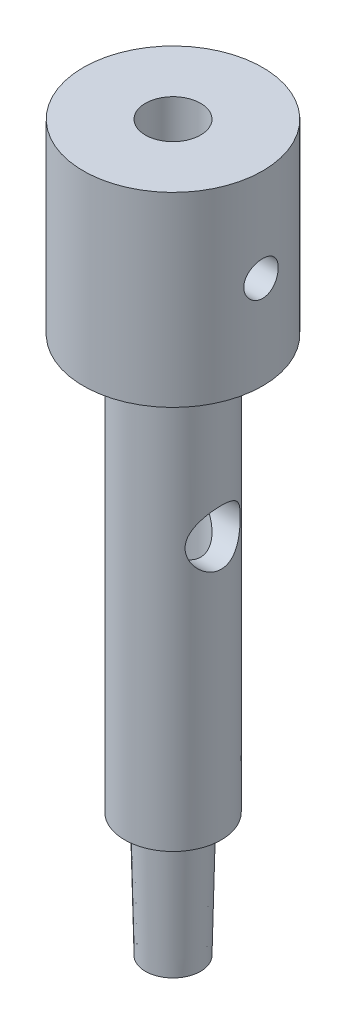
from build123d import *

# Parameters (mm, degrees)
SKETCH_2_R            = 2
CUT_EXTRUDE_1_DEPTH   = 3.5
HOLE_WIZARD_M31_D     = 2.5
HOLE_WIZARD_M31_DEPTH = 6
HOLE_WIZARD_M31_TIP   = 0.751075774


with BuildPart() as part:
    # Эскиз1 → Повернуть1 (revolve)
    with BuildSketch(Plane.XY):
        Polygon((-2, -34.780816616), (-1.25, -34.780816616), (-1.25, -19.23146208), (-2, -18.780816616), (-2, 17.719183384), (-6.5, 17.719183384), (-6.5, 4.219183384), (-3.5, 4.219183384), (-3.5, -25.780816616), (-2.2, -25.780816616), align=None)
    revolve(axis=Axis((0, 17.719183384, 0), (0, -1, 0)))

    # Эскиз2 → Вырез-Вытянуть1 (cut)
    with BuildSketch(Plane(origin=(3.5, 0, 0), x_dir=(0, 0, -1), z_dir=(1, 0, 0))):
        with Locations((0, -6.780816616)):
            Circle(SKETCH_2_R)
    extrude(amount=-CUT_EXTRUDE_1_DEPTH, mode=Mode.SUBTRACT)

    # Отверстие обработанное метчиком M31
    with Locations(Plane(origin=(6.5, 0, 0), x_dir=(0, 0, -1), z_dir=(1, 0, 0))):
        with Locations((0, 10.969183384)):
            Hole(HOLE_WIZARD_M31_D / 2, depth=HOLE_WIZARD_M31_DEPTH)
            with Locations((0, 0, -(HOLE_WIZARD_M31_DEPTH + HOLE_WIZARD_M31_TIP / 2))):  # 118° drill point
                Cone(0, HOLE_WIZARD_M31_D / 2, HOLE_WIZARD_M31_TIP, mode=Mode.SUBTRACT)


solid = part.part
